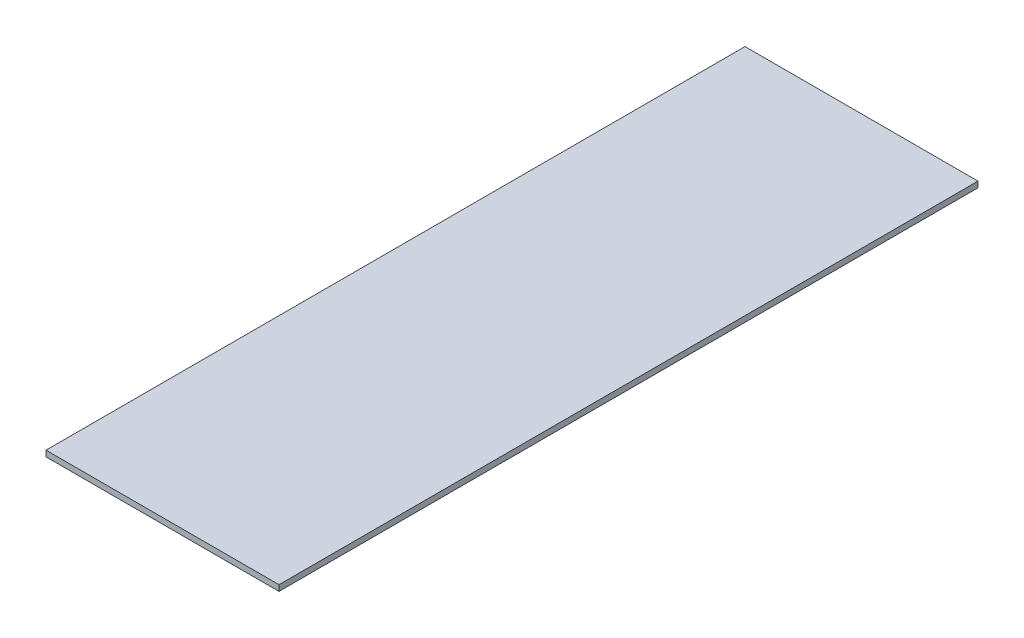
from build123d import *

# Parameters (mm, degrees)
BOSS_EXTRUDE1_DEPTH      = 3.175
BOSS_EXTRUDE1_DEPTH_BACK = 3.175
SKETCH1_W                = 254
SKETCH1_H                = 762


with BuildPart() as part:
    # Sketch1 → Boss-Extrude1 (new, two sides: drawn at the far end of the back side and taken through both)
    with BuildSketch(Plane(origin=(0, 0, 0), x_dir=(1, 0, 0), z_dir=(0, 1, 0)).offset(-BOSS_EXTRUDE1_DEPTH_BACK)):
        Rectangle(SKETCH1_W, SKETCH1_H)
    extrude(amount=BOSS_EXTRUDE1_DEPTH + BOSS_EXTRUDE1_DEPTH_BACK)


solid = part.part
